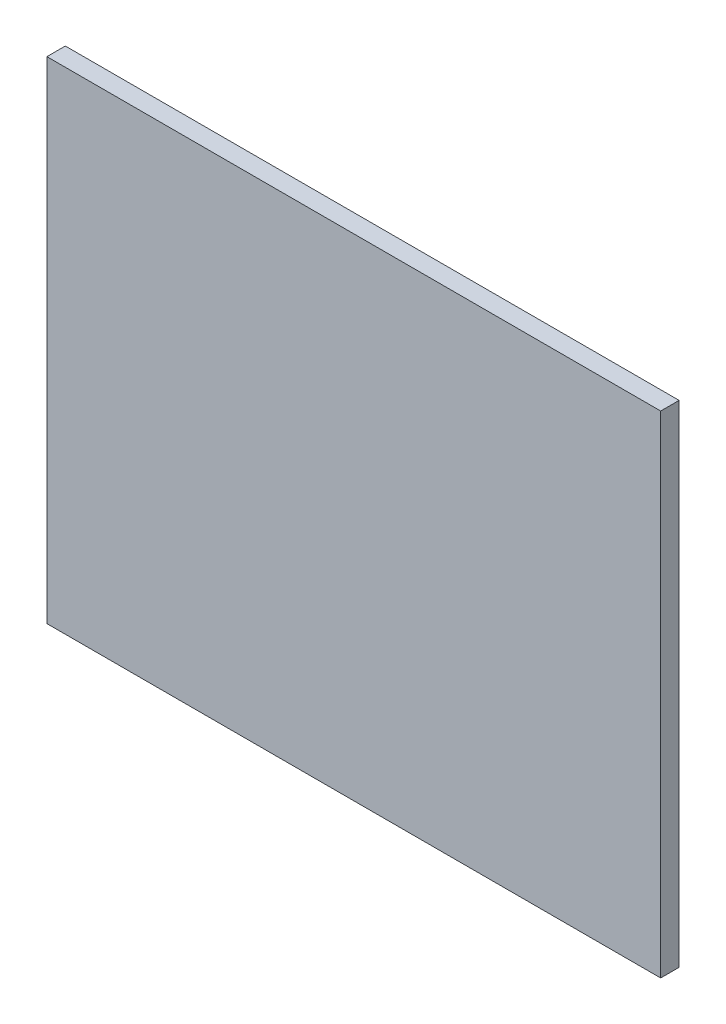
from build123d import *

# Parameters (mm, degrees)
ESBO_O1_W                = 100
ESBO_O1_H                = 80
RESSALTO_EXTRUS_O1_DEPTH = 3


with BuildPart() as part:
    # Esboço1 → Ressalto-extrusão1 (new body)
    with BuildSketch(Plane.XY):
        with Locations((44.647887324, -36.76056338)):
            Rectangle(ESBO_O1_W, ESBO_O1_H)
    extrude(amount=RESSALTO_EXTRUS_O1_DEPTH)


solid = part.part
